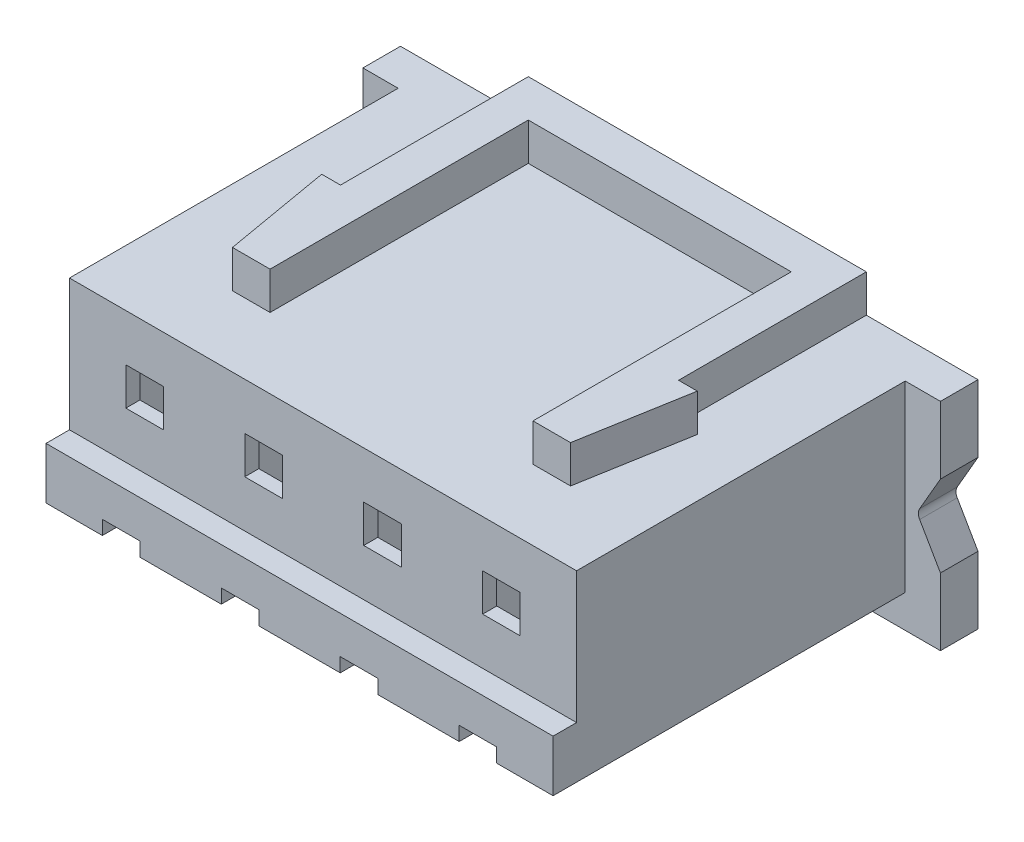
from build123d import *

# Parameters (mm, degrees)
SKETCH1_W           = 10.8
SKETCH1_H           = 4.3
BOSS_EXTRUDE1_DEPTH = 7
SKETCH2_W           = 12.3
SKETCH2_H           = 4.6
BOSS_EXTRUDE2_DEPTH = 0.8
CUT_EXTRUDE1_DEPTH  = 1
FILLET1_R           = 0.2
SKETCH4_W           = 10.8
SKETCH4_H           = 1.5
BOSS_EXTRUDE3_DEPTH = 0.5
SKETCH5_W           = 0.8
SKETCH5_H           = 0.7
CUT_EXTRUDE2_DEPTH  = 3.2
SKETCH6_W           = 0.8
SKETCH6_H           = 0.8
CUT_EXTRUDE3_DEPTH  = 10
BOSS_EXTRUDE4_DEPTH = 0.8
CUT_EXTRUDE4_DEPTH  = 7.5
CUT_EXTRUDE5_DEPTH  = 0.4
BOSS_EXTRUDE5_DEPTH = 0.1


with BuildPart() as part:
    # Sketch1 → Boss-Extrude1 (new body)
    with BuildSketch(Plane.XY):
        Rectangle(SKETCH1_W, SKETCH1_H)
    extrude(amount=BOSS_EXTRUDE1_DEPTH)

    # Sketch2 → Boss-Extrude2 (add)
    with BuildSketch(Plane(origin=(0, 0, 0), x_dir=(-1, 0, 0), z_dir=(0, 0, -1))):
        with Locations((0, -0.15)):
            Rectangle(SKETCH2_W, SKETCH2_H)
    extrude(amount=BOSS_EXTRUDE2_DEPTH)

    # Sketch3 → Cut-Extrude1 (cut)
    with BuildSketch(Plane.XY):
        Polygon((5.65, -0.15), (6.15, -1.016025404), (6.15, 0.716025404), align=None)
    extrude(amount=-CUT_EXTRUDE1_DEPTH, mode=Mode.SUBTRACT)

    # Fillet1
    fillet1_edges = [part.edges().sort_by_distance(p)[0] for p in [
        (5.65, -0.15, -0.4),
    ]]
    fillet(fillet1_edges, radius=FILLET1_R)

    # Sketch4 → Boss-Extrude3 (add)
    with BuildSketch(Plane.XY.offset(7)):
        with Locations((0, -1.4)):
            Rectangle(SKETCH4_W, SKETCH4_H)
    extrude(amount=BOSS_EXTRUDE3_DEPTH)

    # Sketch5 → Cut-Extrude2 (cut)
    with BuildSketch(Plane.XY.offset(7.5)):
        with Locations((-3.8, -1.8)):
            Rectangle(SKETCH5_W, SKETCH5_H)
        with Locations((-1.266666667, -1.8)):
            Rectangle(SKETCH5_W, SKETCH5_H)
        with Locations((1.266666667, -1.8)):
            Rectangle(SKETCH5_W, SKETCH5_H)
        with Locations((3.8, -1.8)):
            Rectangle(SKETCH5_W, SKETCH5_H)
    extrude(amount=-CUT_EXTRUDE2_DEPTH, mode=Mode.SUBTRACT)

    # Sketch6 → Cut-Extrude3 (cut)
    with BuildSketch(Plane.XY.offset(7)):
        with Locations((-3.8, 0.75)):
            Rectangle(SKETCH6_W, SKETCH6_H)
        with Locations((-1.266666667, 0.75)):
            Rectangle(SKETCH6_W, SKETCH6_H)
        with Locations((1.266666667, 0.75)):
            Rectangle(SKETCH6_W, SKETCH6_H)
        with Locations((3.8, 0.75)):
            Rectangle(SKETCH6_W, SKETCH6_H)
    extrude(amount=-CUT_EXTRUDE3_DEPTH, mode=Mode.SUBTRACT)

    # Sketch7 → Boss-Extrude4 (add)
    with BuildSketch(Plane(origin=(0, 2.15, 0), x_dir=(1, 0, 0), z_dir=(0, 1, 0))):
        Polygon((-3.427970594, -5.5), (-3.827970594, -3.2), (-3.427970594, -3.2), (-3.427970594, 0.8), (3.772029406, 0.8), (3.772029406, -3.2), (4.172029406, -3.2), (3.772029406, -5.5), (2.972029406, -5.5), (2.972029406, 0), (-2.627970594, 0), (-2.627970594, -5.5), align=None)
    extrude(amount=BOSS_EXTRUDE4_DEPTH)

    # Sketch8 → Cut-Extrude4 (cut)
    with BuildSketch(Plane(origin=(0, 0, -0.8), x_dir=(-1, 0, 0), z_dir=(0, 0, -1))):
        Polygon((4.9, 1.75), (2.7, 1.75), (2.7, -1.05), (3.4, -1.05), (3.4, -1.45), (4.2, -1.45), (4.2, -1.05), (4.9, -1.05), align=None)
        Polygon((0.166666667, 1.75), (0.166666667, -1.05), (0.866666667, -1.05), (0.866666667, -1.45), (1.666666667, -1.45), (1.666666667, -1.05), (2.366666667, -1.05), (2.366666667, 1.75), align=None)
        Polygon((-2.366666667, 1.75), (-2.366666667, -1.05), (-1.666666667, -1.05), (-1.666666667, -1.45), (-0.866666667, -1.45), (-0.866666667, -1.05), (-0.163333333, -1.05), (-0.163333333, 1.75), align=None)
        Polygon((-4.9, 1.75), (-4.9, -1.05), (-4.2, -1.05), (-4.2, -1.45), (-3.4, -1.45), (-3.4, -1.05), (-2.7, -1.05), (-2.7, 1.75), align=None)
    extrude(amount=-CUT_EXTRUDE4_DEPTH, mode=Mode.SUBTRACT)

    # Sketch9 → Cut-Extrude5 (cut)
    with BuildSketch(Plane.XZ.offset(2.15)):
        Polygon((4.2, 4.3), (3.4, 4.3), (3.4, 7.5), (1.666666667, 7.5), (1.666666667, 4.3), (0.866666667, 4.3), (0.866666667, 7.5), (-0.866666667, 7.5), (-0.866666667, 4.3), (-1.666666667, 4.3), (-1.666666667, 7.5), (-3.4, 7.5), (-3.4, 4.3), (-4.2, 4.3), (-4.2, 7.5), (-5.4, 7.5), (-5.4, 0), (5.4, 0), (5.4, 7.5), (4.2, 7.5), align=None)
    extrude(amount=-CUT_EXTRUDE5_DEPTH, mode=Mode.SUBTRACT)

    # Sketch10 → Boss-Extrude5 (add)
    with BuildSketch(Plane(origin=(0, 0, -0.8), x_dir=(-1, 0, 0), z_dir=(0, 0, -1))):
        Polygon((-3.943958475, -1.663325944), (-3.851510558, -1.663325944), (-3.851510558, -2.163325944), (-3.896382353, -2.163325944), (-3.896382353, -1.714607995), (-3.97330543, -1.714607995), align=None)
        with BuildLine():
            Line((-1.486125943, -1.817172097), (-1.530997738, -1.817172097))
            add(Edge.make_bspline(
                [(-1.530997738, -1.817172097), (-1.530705287, -1.811219114), (-1.530130922, -1.799527611), (-1.527441167, -1.782481339), (-1.52359247, -1.766187796), (-1.518150834, -1.750777809), (-1.511392794, -1.736115122), (-1.503288504, -1.722257977), (-1.493689383, -1.709259236), (-1.482802707, -1.697239401), (-1.470978615, -1.686212605), (-1.458220624, -1.676690427), (-1.444814192, -1.668645046), (-1.430799992, -1.661919154), (-1.416019911, -1.656870605), (-1.400608074, -1.653124656), (-1.384496769, -1.650870893), (-1.373519623, -1.650628637), (-1.36793684, -1.650505431)],
                knots=[0, 0, 0, 0, 1.7869e-05, 3.5094e-05, 5.1686e-05, 6.8032e-05, 8.4031e-05, 0.000100058, 0.000116104, 0.000132416, 0.000148647, 0.000164532, 0.000180078, 0.00019549, 0.000211074, 0.000226841, 0.000243017, 0.000259759, 0.000259759, 0.000259759, 0.000259759], degree=3))
            add(Edge.make_bspline(
                [(-1.36793684, -1.650505431), (-1.362454258, -1.650633782), (-1.35168118, -1.650885987), (-1.335958035, -1.653051848), (-1.320989851, -1.656444075), (-1.306805884, -1.661203421), (-1.293519303, -1.667601196), (-1.281030297, -1.675286559), (-1.269190181, -1.684175106), (-1.258532069, -1.694639936), (-1.248745201, -1.705811706), (-1.240302021, -1.717738549), (-1.233071569, -1.730057018), (-1.227044758, -1.742861047), (-1.222608167, -1.756271194), (-1.219239851, -1.770092223), (-1.217335935, -1.784467196), (-1.217043732, -1.794196704), (-1.216895174, -1.799143251)],
                knots=[0, 0, 0, 0, 1.6441e-05, 3.2306e-05, 4.7516e-05, 6.2435e-05, 7.7085e-05, 9.1652e-05, 0.000106376, 0.000121393, 0.000136374, 0.000150882, 0.000165157, 0.000179183, 0.000193247, 0.000207458, 0.000221808, 0.000236648, 0.000236648, 0.000236648, 0.000236648], degree=3))
            add(Edge.make_bspline(
                [(-1.216895174, -1.799143251), (-1.217137068, -1.806107228), (-1.217616613, -1.819912973), (-1.221718667, -1.84020081), (-1.228125311, -1.859857013), (-1.235839219, -1.875676627), (-1.243620997, -1.888424269), (-1.250633498, -1.898919799), (-1.258842757, -1.91022058), (-1.268368256, -1.922288771), (-1.279012952, -1.9352189), (-1.290873261, -1.949003157), (-1.304033759, -1.963499124), (-1.313270687, -1.973399924), (-1.318057033, -1.978530271)],
                knots=[0, 0, 0, 0, 2.0874e-05, 4.1382e-05, 6.1843e-05, 8.2763e-05, 9.3997e-05, 0.000106637, 0.000120621, 0.000135888, 0.000152753, 0.000170863, 0.000190435, 0.000211484, 0.000211484, 0.000211484, 0.000211484], degree=3))
            Line((-1.318057033, -1.978530271), (-1.443157193, -2.112043892))
            Line((-1.443157193, -2.112043892), (-1.210484917, -2.112043892))
            Line((-1.210484917, -2.112043892), (-1.210484917, -2.163325944))
            Line((-1.210484917, -2.163325944), (-1.550228507, -2.163325944))
            Line((-1.550228507, -2.163325944), (-1.35631825, -1.956394854))
            add(Edge.make_bspline(
                [(-1.35631825, -1.956394854), (-1.351597124, -1.951466524), (-1.342528806, -1.942000212), (-1.329702723, -1.928179789), (-1.318182868, -1.915358426), (-1.307894669, -1.903560348), (-1.299061311, -1.892612981), (-1.291222421, -1.88287088), (-1.284941622, -1.873905959), (-1.278125137, -1.863514443), (-1.271523139, -1.850826969), (-1.265849946, -1.835322156), (-1.262390682, -1.81936112), (-1.261975705, -1.808575115), (-1.261766968, -1.803149662)],
                knots=[0, 0, 0, 0, 2.0474e-05, 3.9327e-05, 5.6561e-05, 7.2184e-05, 8.6278e-05, 9.8762e-05, 0.000109683, 0.000119101, 0.000136035, 0.000152448, 0.000168517, 0.00018478, 0.00018478, 0.00018478, 0.00018478], degree=3))
            add(Edge.make_bspline(
                [(-1.261766968, -1.803149662), (-1.261857789, -1.799738033), (-1.262036778, -1.793014369), (-1.263616449, -1.783156403), (-1.266003664, -1.773647144), (-1.269424416, -1.764457341), (-1.273939664, -1.755679391), (-1.279435861, -1.747302608), (-1.285777299, -1.739204185), (-1.293113195, -1.731610856), (-1.301171983, -1.724656398), (-1.309685447, -1.718495815), (-1.318692605, -1.71334737), (-1.32815548, -1.709126871), (-1.33804769, -1.705816102), (-1.348388367, -1.703522019), (-1.359148941, -1.702081664), (-1.366496583, -1.701886783), (-1.370240526, -1.701787482)],
                knots=[0, 0, 0, 0, 1.0229e-05, 2.0159e-05, 2.9876e-05, 3.9606e-05, 4.9505e-05, 5.9423e-05, 6.9622e-05, 8.0319e-05, 9.1042e-05, 0.000101521, 0.000111795, 0.000122107, 0.000132559, 0.000143032, 0.000153841, 0.00016507, 0.00016507, 0.00016507, 0.00016507], degree=3))
            add(Edge.make_bspline(
                [(-1.370240526, -1.701787482), (-1.374150645, -1.70188963), (-1.381829473, -1.70209023), (-1.393103621, -1.703493468), (-1.403858732, -1.705914302), (-1.414121861, -1.709225256), (-1.423910373, -1.71343362), (-1.433176665, -1.718675298), (-1.441899935, -1.724930083), (-1.450096581, -1.732021591), (-1.457648578, -1.739916962), (-1.464283846, -1.748718385), (-1.470081562, -1.758265159), (-1.475140024, -1.768531523), (-1.47924798, -1.779610635), (-1.482387002, -1.791463164), (-1.484870837, -1.804037647), (-1.485700625, -1.812721231), (-1.486125943, -1.817172097)],
                knots=[0, 0, 0, 0, 1.1729e-05, 2.3035e-05, 3.4018e-05, 4.4756e-05, 5.5343e-05, 6.5928e-05, 7.6628e-05, 8.7492e-05, 9.8403e-05, 0.00010934, 0.000120489, 0.000131867, 0.000143625, 0.00015587, 0.000168619, 0.000182025, 0.000182025, 0.000182025, 0.000182025], degree=3))
        make_face()
        with BuildLine():
            Line((1.20618175, -1.778710559), (1.161309955, -1.778710559))
            add(Edge.make_bspline(
                [(1.161309955, -1.778710559), (1.162525605, -1.773677347), (1.164902101, -1.763837829), (1.169858897, -1.749779649), (1.175258791, -1.736476289), (1.181742949, -1.72417685), (1.188815628, -1.712634149), (1.196918874, -1.702109989), (1.205678834, -1.692336708), (1.215368113, -1.683663388), (1.22552935, -1.675809427), (1.236305724, -1.66911299), (1.247480424, -1.663352397), (1.259130871, -1.65860665), (1.271291753, -1.655031575), (1.283853128, -1.652437745), (1.296847913, -1.650753301), (1.305668998, -1.650588906), (1.310148096, -1.650505431)],
                knots=[0, 0, 0, 0, 1.5524e-05, 3.0347e-05, 4.467e-05, 5.8558e-05, 7.201e-05, 8.5231e-05, 9.8349e-05, 0.000111325, 0.000124187, 0.000136831, 0.000149329, 0.000161865, 0.00017451, 0.000187298, 0.000200318, 0.000213748, 0.000213748, 0.000213748, 0.000213748], degree=3))
            add(Edge.make_bspline(
                [(1.310148096, -1.650505431), (1.316674202, -1.650702464), (1.32958406, -1.651092232), (1.34855021, -1.654651437), (1.366839756, -1.660283599), (1.384252505, -1.66806556), (1.400426567, -1.677663747), (1.414817451, -1.689087281), (1.427230095, -1.702115753), (1.437643578, -1.716506119), (1.445797149, -1.731885478), (1.451809488, -1.747714071), (1.455469728, -1.763954353), (1.455944094, -1.774919679), (1.45618175, -1.780413283)],
                knots=[0, 0, 0, 0, 1.9562e-05, 3.8698e-05, 5.7675e-05, 7.6865e-05, 9.5777e-05, 0.000113954, 0.000131807, 0.000149598, 0.000167073, 0.000183872, 0.000200276, 0.000216747, 0.000216747, 0.000216747, 0.000216747], degree=3))
            add(Edge.make_bspline(
                [(1.45618175, -1.780413283), (1.456015522, -1.785699968), (1.455690241, -1.79604519), (1.452928283, -1.811148261), (1.448280246, -1.825382776), (1.441841708, -1.838808656), (1.433507201, -1.851340776), (1.423411101, -1.863007332), (1.41148215, -1.873860069), (1.402442302, -1.880077136), (1.39778832, -1.883277867)],
                knots=[0, 0, 0, 0, 1.5851e-05, 3.1018e-05, 4.5873e-05, 6.0656e-05, 7.5546e-05, 9.0886e-05, 0.000106841, 0.00012377, 0.00012377, 0.00012377, 0.00012377], degree=3))
            add(Edge.make_bspline(
                [(1.39778832, -1.883277867), (1.403107142, -1.885846177), (1.413645267, -1.890934742), (1.428009628, -1.900914136), (1.441049325, -1.912436472), (1.448321285, -1.921428279), (1.451975019, -1.925946136)],
                knots=[0, 0, 0, 0, 1.7695e-05, 3.5058e-05, 5.2293e-05, 6.9697e-05, 6.9697e-05, 6.9697e-05, 6.9697e-05], degree=3))
            add(Edge.make_bspline(
                [(1.451975019, -1.925946136), (1.454380925, -1.9292401), (1.459153339, -1.935774089), (1.465044129, -1.946279292), (1.470388288, -1.956900934), (1.474552605, -1.967923706), (1.477777443, -1.979219851), (1.480082591, -1.990808764), (1.481514611, -2.00269991), (1.48171969, -2.01074455), (1.481822775, -2.014788283)],
                knots=[0, 0, 0, 0, 1.2226e-05, 2.4252e-05, 3.6078e-05, 4.7871e-05, 5.9538e-05, 7.1285e-05, 8.3286e-05, 9.5416e-05, 9.5416e-05, 9.5416e-05, 9.5416e-05], degree=3))
            add(Edge.make_bspline(
                [(1.481822775, -2.014788283), (1.481566416, -2.021789672), (1.481054904, -2.035759501), (1.476482894, -2.056398747), (1.469395288, -2.076573819), (1.459330011, -2.095870224), (1.447063224, -2.113924564), (1.432469321, -2.130078323), (1.41571412, -2.143963838), (1.397027598, -2.155565299), (1.376782294, -2.164839288), (1.355128638, -2.171276065), (1.332378631, -2.175468351), (1.316777588, -2.175917904), (1.308846012, -2.176146456)],
                knots=[0, 0, 0, 0, 2.098e-05, 4.1862e-05, 6.3119e-05, 8.498e-05, 0.000106955, 0.000128441, 0.000150062, 0.000172018, 0.00019425, 0.000216652, 0.00023964, 0.000263413, 0.000263413, 0.000263413, 0.000263413], degree=3))
            add(Edge.make_bspline(
                [(1.308846012, -2.176146456), (1.303500398, -2.176022426), (1.292982012, -2.175778375), (1.277518655, -2.174110004), (1.262758412, -2.17106286), (1.248681326, -2.166962388), (1.235274893, -2.161763568), (1.222580021, -2.155289468), (1.210518607, -2.147673539), (1.199204471, -2.138825884), (1.188638962, -2.128928549), (1.179102858, -2.117805834), (1.170437173, -2.105663347), (1.162873939, -2.092360054), (1.15606866, -2.078067874), (1.150471381, -2.062603803), (1.145544871, -2.046106086), (1.143254376, -2.034609265), (1.142079185, -2.028710559)],
                knots=[0, 0, 0, 0, 1.6037e-05, 3.1555e-05, 4.6582e-05, 6.1194e-05, 7.5497e-05, 8.9652e-05, 0.000103879, 0.000118224, 0.000132679, 0.000147236, 0.000162105, 0.000177361, 0.000193087, 0.000209535, 0.00022665, 0.000244684, 0.000244684, 0.000244684, 0.000244684], degree=3))
            Line((1.142079185, -2.028710559), (1.18695098, -2.028710559))
            add(Edge.make_bspline(
                [(1.18695098, -2.028710559), (1.188120022, -2.032560418), (1.190393909, -2.040048728), (1.194264523, -2.050825915), (1.198674277, -2.060705637), (1.203404928, -2.069760368), (1.208373277, -2.078079283), (1.213932552, -2.085442407), (1.219671002, -2.09217315), (1.223996624, -2.095965238), (1.226113641, -2.097821136)],
                knots=[0, 0, 0, 0, 1.207e-05, 2.3476e-05, 3.4328e-05, 4.4497e-05, 5.4117e-05, 6.3352e-05, 7.2152e-05, 8.0588e-05, 8.0588e-05, 8.0588e-05, 8.0588e-05], degree=3))
            add(Edge.make_bspline(
                [(1.226113641, -2.097821136), (1.228913151, -2.099979469), (1.234503532, -2.104289474), (1.243613279, -2.109789707), (1.253193977, -2.114555567), (1.263453216, -2.118196095), (1.274169612, -2.121278618), (1.285516379, -2.123295835), (1.29739341, -2.12467986), (1.30550309, -2.124801993), (1.309647294, -2.124864405)],
                knots=[0, 0, 0, 0, 1.0597e-05, 2.1162e-05, 3.1867e-05, 4.2641e-05, 5.3771e-05, 6.5283e-05, 7.7174e-05, 8.96e-05, 8.96e-05, 8.96e-05, 8.96e-05], degree=3))
            add(Edge.make_bspline(
                [(1.309647294, -2.124864405), (1.314326366, -2.124776419), (1.323475887, -2.124604369), (1.336826581, -2.123022125), (1.349527645, -2.12071778), (1.361438063, -2.117158783), (1.37271385, -2.112761518), (1.383196943, -2.107240317), (1.393024958, -2.1007625), (1.402072016, -2.093399763), (1.410207088, -2.085339549), (1.417369876, -2.076909111), (1.423459113, -2.068143992), (1.428371053, -2.058995689), (1.432249703, -2.049502085), (1.43489016, -2.039636538), (1.436726091, -2.029479786), (1.436875607, -2.022575647), (1.43695098, -2.019095174)],
                knots=[0, 0, 0, 0, 1.4031e-05, 2.7437e-05, 4.0284e-05, 5.2708e-05, 6.4668e-05, 7.654e-05, 8.818e-05, 9.9927e-05, 0.000111472, 0.000122488, 0.000133073, 0.000143425, 0.000153581, 0.000163762, 0.000174021, 0.000184449, 0.000184449, 0.000184449, 0.000184449], degree=3))
            add(Edge.make_bspline(
                [(1.43695098, -2.019095174), (1.436732366, -2.014436412), (1.436296225, -2.005142068), (1.432966428, -1.991468129), (1.427489447, -1.978293355), (1.419821945, -1.965842528), (1.41048827, -1.954303114), (1.399578997, -1.944007188), (1.387003536, -1.93551146), (1.375429269, -1.929641652), (1.365177104, -1.925636356), (1.356403478, -1.922968504), (1.346581106, -1.92070941), (1.33582877, -1.918607657), (1.324065454, -1.916818893), (1.311303962, -1.915327205), (1.297541711, -1.914133628), (1.288014401, -1.913600614), (1.283104826, -1.913325944)],
                knots=[0, 0, 0, 0, 1.3966e-05, 2.7862e-05, 4.1962e-05, 5.6614e-05, 7.1569e-05, 8.6379e-05, 0.000101437, 0.000116935, 0.000125212, 0.000134432, 0.000144417, 0.000155437, 0.000167294, 0.000180102, 0.000193977, 0.000208728, 0.000208728, 0.000208728, 0.000208728], degree=3))
            Line((1.283104826, -1.913325944), (1.283104826, -1.862043892))
            add(Edge.make_bspline(
                [(1.283104826, -1.862043892), (1.289290707, -1.86193892), (1.301407328, -1.861733306), (1.319106515, -1.859246447), (1.336031273, -1.855806358), (1.351806522, -1.850537045), (1.36618491, -1.844417002), (1.378659139, -1.837295258), (1.389054446, -1.829378865), (1.397320313, -1.820545635), (1.403538774, -1.811072057), (1.40808546, -1.801198249), (1.41077122, -1.790837669), (1.411129744, -1.783767002), (1.411309955, -1.780212963)],
                knots=[0, 0, 0, 0, 1.8543e-05, 3.6321e-05, 5.353e-05, 7.0285e-05, 8.612e-05, 0.000100345, 0.000113267, 0.000125173, 0.000136452, 0.00014712, 0.000157663, 0.000168319, 0.000168319, 0.000168319, 0.000168319], degree=3))
            add(Edge.make_bspline(
                [(1.411309955, -1.780212963), (1.411250753, -1.777601856), (1.411132974, -1.772407184), (1.409647649, -1.764817888), (1.407415643, -1.75746061), (1.40434711, -1.750366638), (1.400239939, -1.74358517), (1.395324798, -1.737058391), (1.389472212, -1.730823566), (1.38276572, -1.725012092), (1.375564034, -1.719473629), (1.367671209, -1.714771681), (1.359325226, -1.710750958), (1.350516847, -1.707435315), (1.341217486, -1.704941131), (1.331470835, -1.703150296), (1.321258308, -1.702030631), (1.314290918, -1.701869429), (1.310749057, -1.701787482)],
                knots=[0, 0, 0, 0, 7.823e-06, 1.5563e-05, 2.3104e-05, 3.0863e-05, 3.8679e-05, 4.6832e-05, 5.5336e-05, 6.4278e-05, 7.3432e-05, 8.2553e-05, 9.1782e-05, 0.000101195, 0.000110744, 0.000120626, 0.000130901, 0.000141526, 0.000141526, 0.000141526, 0.000141526], degree=3))
            add(Edge.make_bspline(
                [(1.310749057, -1.701787482), (1.305055962, -1.701986248), (1.293936022, -1.702374484), (1.27790532, -1.705774915), (1.263002558, -1.711200355), (1.25161132, -1.717676501), (1.243199523, -1.72406942), (1.237188532, -1.729652618), (1.231285602, -1.735857307), (1.225879077, -1.743065647), (1.220411366, -1.750789474), (1.215433572, -1.759421428), (1.210596473, -1.768736342), (1.207681823, -1.775321432), (1.20618175, -1.778710559)],
                knots=[0, 0, 0, 0, 1.7063e-05, 3.3328e-05, 4.8919e-05, 6.4486e-05, 7.2419e-05, 8.0571e-05, 8.9075e-05, 9.807e-05, 0.000107572, 0.00011745, 0.000127932, 0.000139048, 0.000139048, 0.000139048, 0.000139048], degree=3))
        make_face()
        Polygon((3.915015884, -1.650505431), (3.924130467, -1.650505431), (3.924130467, -1.996659277), (3.981822775, -1.996659277), (3.981822775, -2.047941328), (3.924130467, -2.047941328), (3.924130467, -2.163325944), (3.879258673, -2.163325944), (3.879258673, -2.047941328), (3.642079185, -2.047941328), align=None)
        Polygon((3.879258673, -1.996659277), (3.879258673, -1.779511841), (3.730220211, -1.996659277), align=None, mode=Mode.SUBTRACT)
    extrude(amount=BOSS_EXTRUDE5_DEPTH)


solid = part.part
